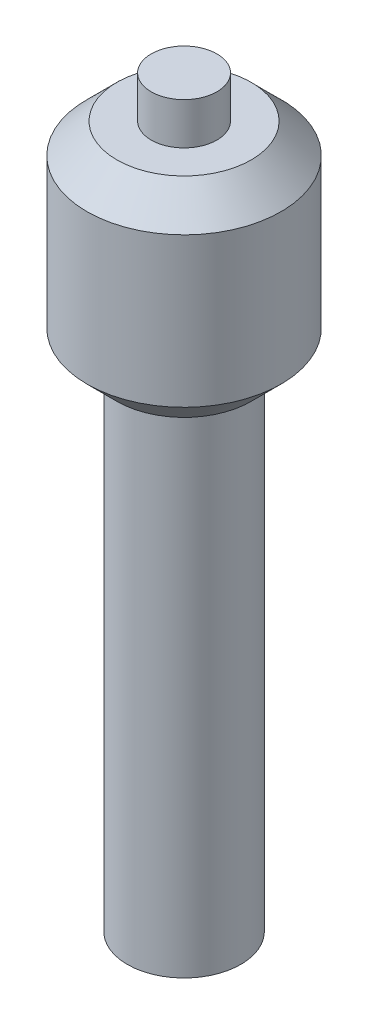
from build123d import *


with BuildPart() as part:
    # Sketch1 → Revolve1 (revolve)
    with BuildSketch(Plane.XY):
        Polygon((11, 264.442482276), (0, 264.442482276), (0, 15.442482276), (19, 15.442482276), (19, 180.442482276), (22.5, 180.442482276), (32.5, 190.442482276), (32.5, 240.442482276), (22.5, 250.442482276), (11, 250.442482276), align=None)
    revolve(axis=Axis((0, 309.181995893, 0), (0, -1, 0)))


solid = part.part
